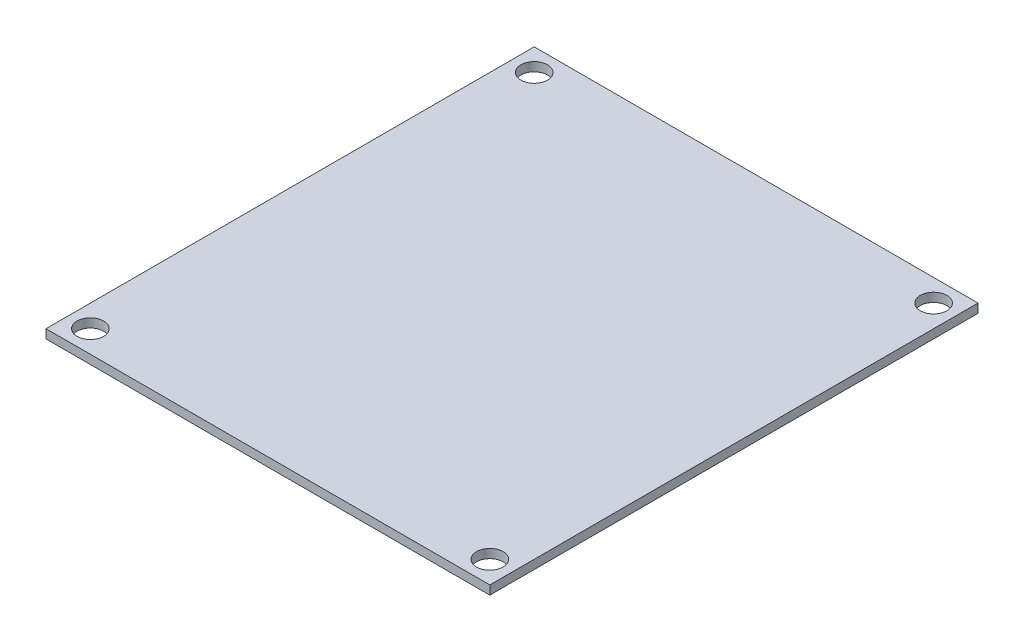
from build123d import *

# Parameters (mm, degrees)
SKETCH1_W           = 50
SKETCH1_H           = 55
BOSS_EXTRUDE1_DEPTH = 1
SKETCH2_R           = 1.5
CUT_EXTRUDE1_DEPTH  = 2


with BuildPart() as part:
    # Sketch1 → Boss-Extrude1 (new body)
    with BuildSketch(Plane(origin=(0, 0, 0), x_dir=(1, 0, 0), z_dir=(0, 1, 0))):
        with Locations((25, -27.5)):
            Rectangle(SKETCH1_W, SKETCH1_H)
    extrude(amount=BOSS_EXTRUDE1_DEPTH)

    # Sketch2 → Cut-Extrude1 (cut, through all)
    with BuildSketch(Plane(origin=(0, 1, 0), x_dir=(1, 0, 0), z_dir=(0, 1, 0))):
        with Locations((2.5, -2.5)):
            Circle(SKETCH2_R)
        with Locations((47.5, -2.5)):
            Circle(SKETCH2_R)
        with Locations((47.5, -52.5)):
            Circle(SKETCH2_R)
        with Locations((2.5, -52.5)):
            Circle(SKETCH2_R)
    extrude(amount=-CUT_EXTRUDE1_DEPTH, mode=Mode.SUBTRACT)


solid = part.part
